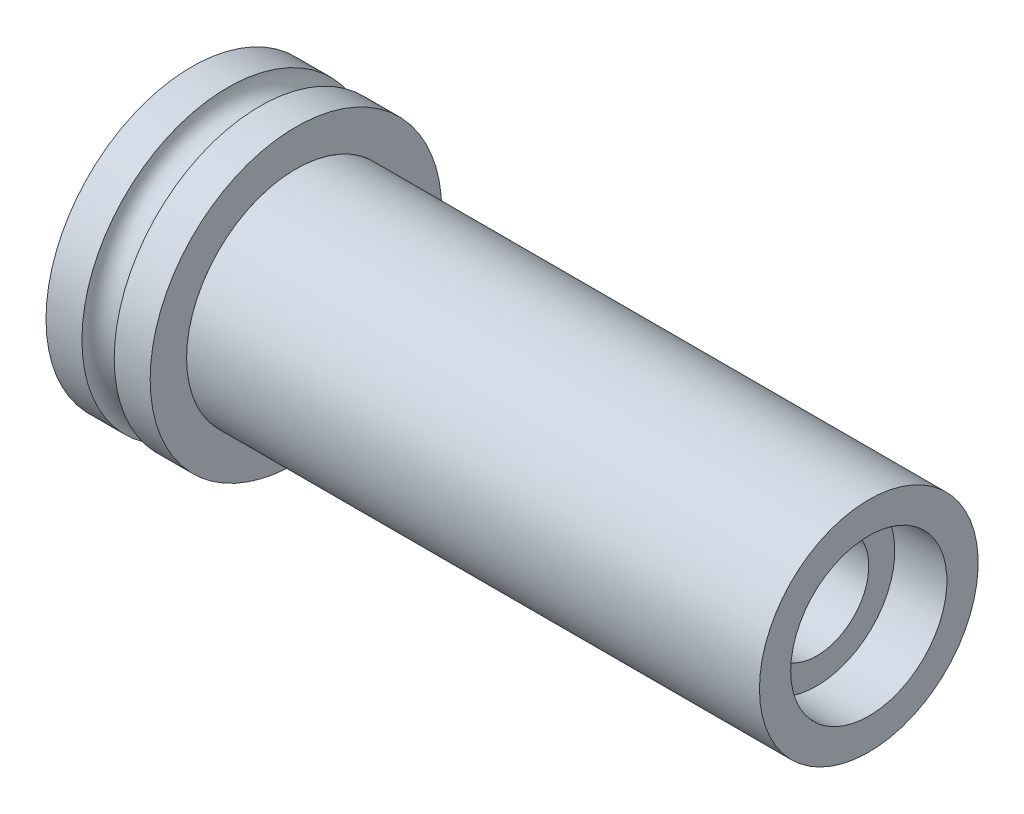
from build123d import *

# Parameters (mm, degrees)
SKETCH2_R           = 14
SKETCH2_R_2         = 10.5
BOSS_EXTRUDE1_DEPTH = 10
SKETCH3_R           = 1.55


with BuildPart() as part:
    # Sketch1 → Revolve1 (revolve)
    with BuildSketch(Plane(origin=(0, 0, 0), x_dir=(1, 0, 0), z_dir=(0, 1, 0))):
        Polygon((-22.5, 7.5), (-22.5, 5), (22.5, 5), (22.5, 7.5), (27.5, 7.5), (27.5, 10.5), (-27.5, 10.5), (-27.5, 7.5), align=None)
    revolve(axis=Axis((-27.5, 0, 0), (1, 0, 0)))


with BuildPart() as body_2:
    # Sketch2 → Boss-Extrude1 (new body)
    with BuildSketch(Plane(origin=(-27.5, 0, 0), x_dir=(0, 0, -1), z_dir=(1, 0, 0))):
        Circle(SKETCH2_R)
        Circle(SKETCH2_R_2, mode=Mode.SUBTRACT)
    extrude(amount=-BOSS_EXTRUDE1_DEPTH)

    # Sketch3 → Cut-Revolve2 (revolve, cut)
    with BuildSketch(Plane.XY):
        with Locations((-32.5, 14)):
            Circle(SKETCH3_R)
    revolve(axis=Axis((0, 0, 0), (1, 0, 0)), mode=Mode.SUBTRACT)


solid = Compound([part.part, body_2.part])
